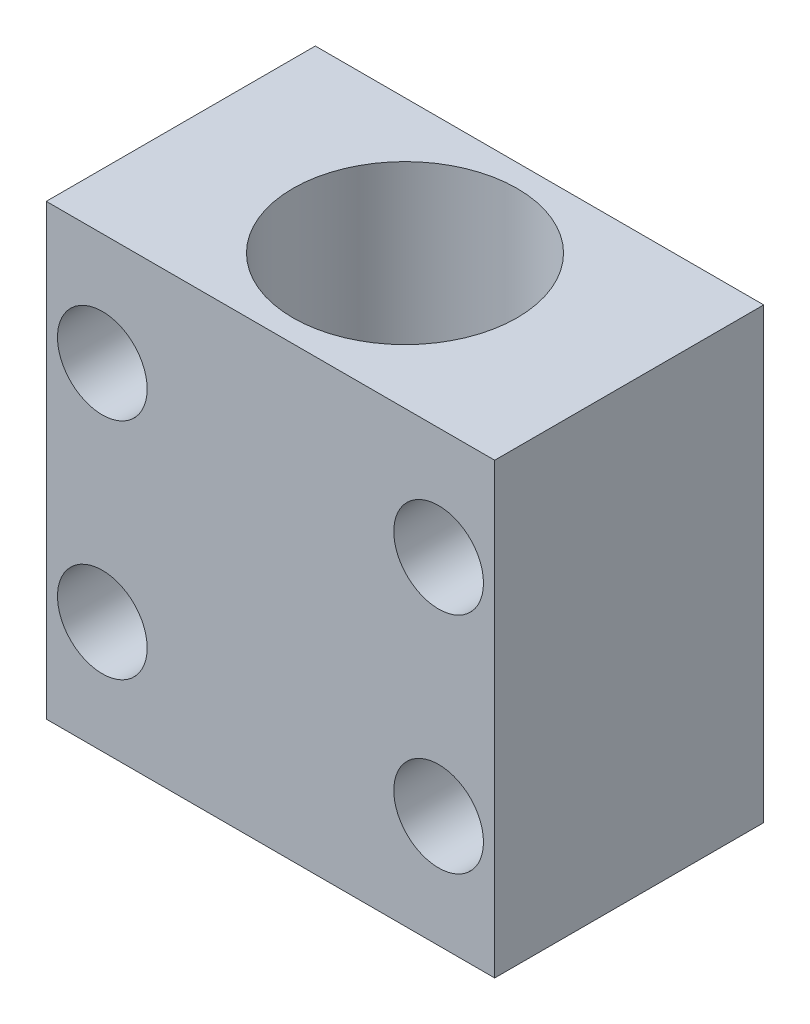
from build123d import *

# Parameters (mm, degrees)
SKETCH2_W           = 127
SKETCH2_H           = 76.2
SKETCH2_R           = 31.75
BOSS_EXTRUDE1_DEPTH = 127
SKETCH3_R           = 12.7
CUT_EXTRUDE1_DEPTH  = 127


with BuildPart() as part:
    # Sketch2 → Boss-Extrude1 (new body)
    with BuildSketch(Plane(origin=(0, 0, 0), x_dir=(1, 0, 0), z_dir=(0, 1, 0))):
        Rectangle(SKETCH2_W, SKETCH2_H)
        Circle(SKETCH2_R, mode=Mode.SUBTRACT)
    extrude(amount=BOSS_EXTRUDE1_DEPTH)

    # Sketch3 → Cut-Extrude1 (cut)
    with BuildSketch(Plane.XY.offset(38.1)):
        with BuildLine():
            ThreePointArc((60.325, 95.25), (56.605256121, 104.230256121), (47.625, 107.95))
            Line((47.625, 107.95), (47.625, 82.55))
            ThreePointArc((47.625, 82.55), (56.605256121, 86.269743879), (60.325, 95.25))
        make_face()
        with BuildLine():
            Line((47.625, 82.55), (47.625, 107.95))
            ThreePointArc((47.625, 107.95), (34.925, 95.25), (47.625, 82.55))
        make_face()
        with BuildLine():
            ThreePointArc((60.325, 31.75), (56.605256121, 40.730256121), (47.625, 44.45))
            Line((47.625, 44.45), (47.625, 19.05))
            ThreePointArc((47.625, 19.05), (56.605256121, 22.769743879), (60.325, 31.75))
        make_face()
        with BuildLine():
            Line((47.625, 19.05), (47.625, 44.45))
            ThreePointArc((47.625, 44.45), (34.925, 31.75), (47.625, 19.05))
        make_face()
        with Locations((-47.625, 31.75)):
            Circle(SKETCH3_R)
        with Locations((-47.625, 95.25)):
            Circle(SKETCH3_R)
    extrude(amount=-CUT_EXTRUDE1_DEPTH, mode=Mode.SUBTRACT)


solid = part.part
